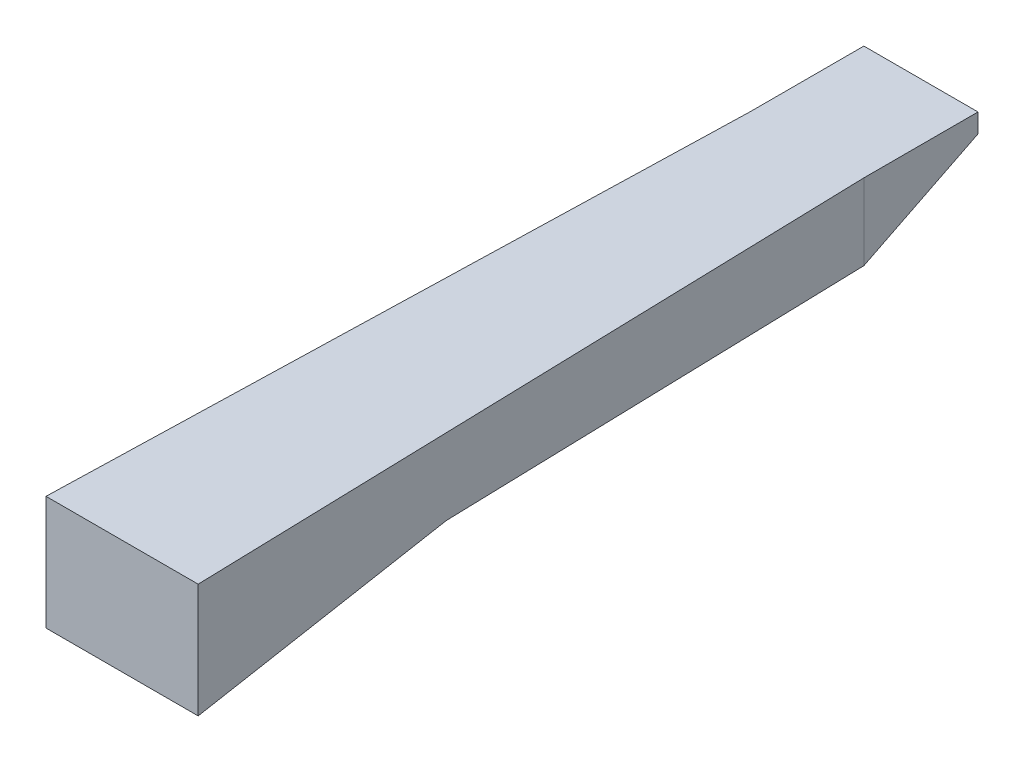
from build123d import *

# Parameters (mm, degrees)
SKETCH1_W           = 38.1
SKETCH1_H           = 38.1
BOSS_EXTRUDE2_DEPTH = 50.8
SKETCH11_W          = 266.7
SKETCH11_H          = 12.7
CUT_EXTRUDE6_DEPTH  = 51.8


with BuildPart() as part:
    # Sketch1 → Boss-Extrude2 (new body)
    with BuildSketch(Plane(origin=(0, 0, 0), x_dir=(1, 0, 0), z_dir=(0, 1, 0))):
        Polygon((-19.05, 114.3), (-25.4, -114.3), (25.4, -114.3), (19.05, 114.3), align=None)
        with Locations((0, 133.35)):
            Rectangle(SKETCH1_W, SKETCH1_H)
    extrude(amount=BOSS_EXTRUDE2_DEPTH)

    # Sketch11 → Cut-Extrude6 (cut, through all)
    with BuildSketch(Plane(origin=(25.4, 0, 0), x_dir=(0, 0, -1), z_dir=(1, 0, 0))):
        Polygon((114.3, 12.7), (-29.077687403, 12.7), (-114.3, 0), (152.4, 0), (152.4, 12.7), align=None)
        with Locations((19.05, 44.45)):
            Rectangle(SKETCH11_W, SKETCH11_H)
        Polygon((152.4, 12.7), (152.4, 31.75), (114.3, 12.7), align=None)
    extrude(amount=-CUT_EXTRUDE6_DEPTH, mode=Mode.SUBTRACT)


solid = part.part
